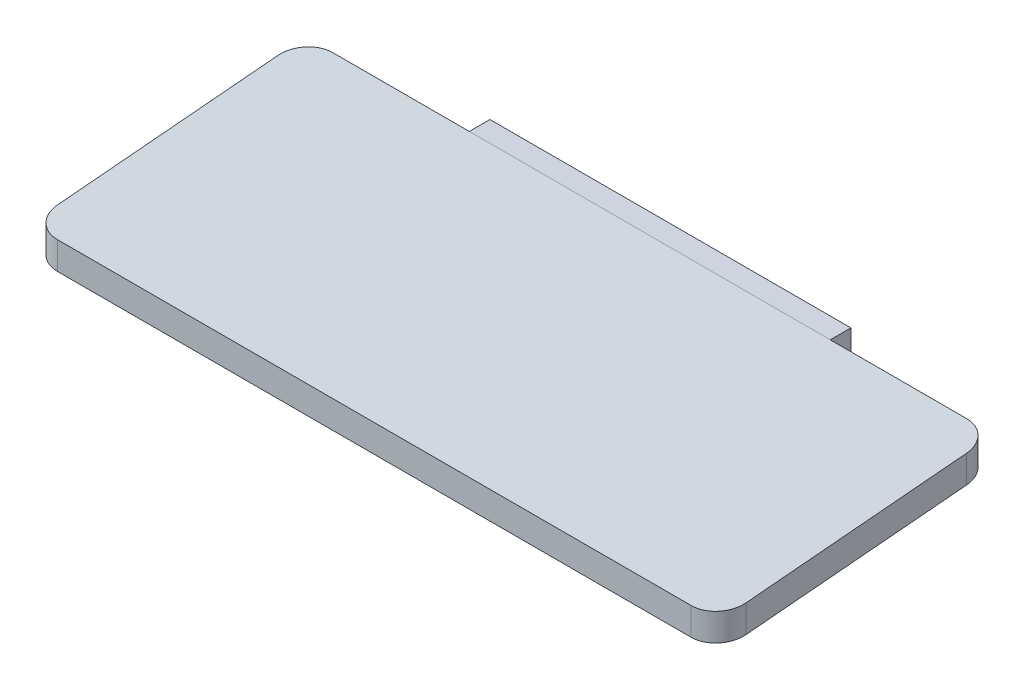
from build123d import *

# Parameters (mm, degrees)
SKETCH3_W           = 26.2
SKETCH3_H           = 16
SKETCH3_R           = 2.1
BOSS_EXTRUDE1_DEPTH = 1.5
BOSS_EXTRUDE2_START = -13.1
BOSS_EXTRUDE2_DEPTH = 25
CHAMFER1_SIZE       = 3
CHAMFER1_SIZE2      = 2.769187039
FILLET1_R           = 2


with BuildPart() as part:
    # Sketch3 → Boss-Extrude1 (new body)
    with BuildSketch(Plane.XY):
        with Locations((0, 47.9)):
            Rectangle(SKETCH3_W, SKETCH3_H)
        with Locations((8, 46)):
            Circle(SKETCH3_R, mode=Mode.SUBTRACT)
        with Locations((-8, 46)):
            Circle(SKETCH3_R, mode=Mode.SUBTRACT)
    extrude(amount=BOSS_EXTRUDE1_DEPTH)

    # Sketch4 → Boss-Extrude2 (add, symmetric)
    with BuildSketch(Plane(origin=(13.1, 0, 0), x_dir=(0, 0, -1), z_dir=(1, 0, 0)).offset(BOSS_EXTRUDE2_START)):
        Polygon((-1.5, 55.9), (-21.5, 54.150226729), (-21.5, 52.150226729), (-1.5, 53.9), align=None)
    extrude(amount=BOSS_EXTRUDE2_DEPTH, both=True)

    # Chamfer1
    chamfer1_edges = [part.edges().sort_by_distance(p)[0] for p in [
        (0, 53.9, 1.5),
    ]]
    chamfer1_side = [part.faces().sort_by_distance(p)[0] for p in [
        (0, 46.973543536, 1.5),
    ]]
    chamfer(chamfer1_edges, length=CHAMFER1_SIZE, length2=CHAMFER1_SIZE2, reference=chamfer1_side[0])

    # Fillet1
    fillet1_edges = [part.edges().sort_by_distance(p)[0] for p in [
        (-25, 54.9, 1.5),
        (-25, 53.150226729, 21.5),
        (25, 54.9, 1.5),
        (25, 53.150226729, 21.5),
        (13.1, 39.9, 0.75),
        (-13.1, 39.9, 0.75),
    ]]
    fillet(fillet1_edges, radius=FILLET1_R)


solid = part.part
